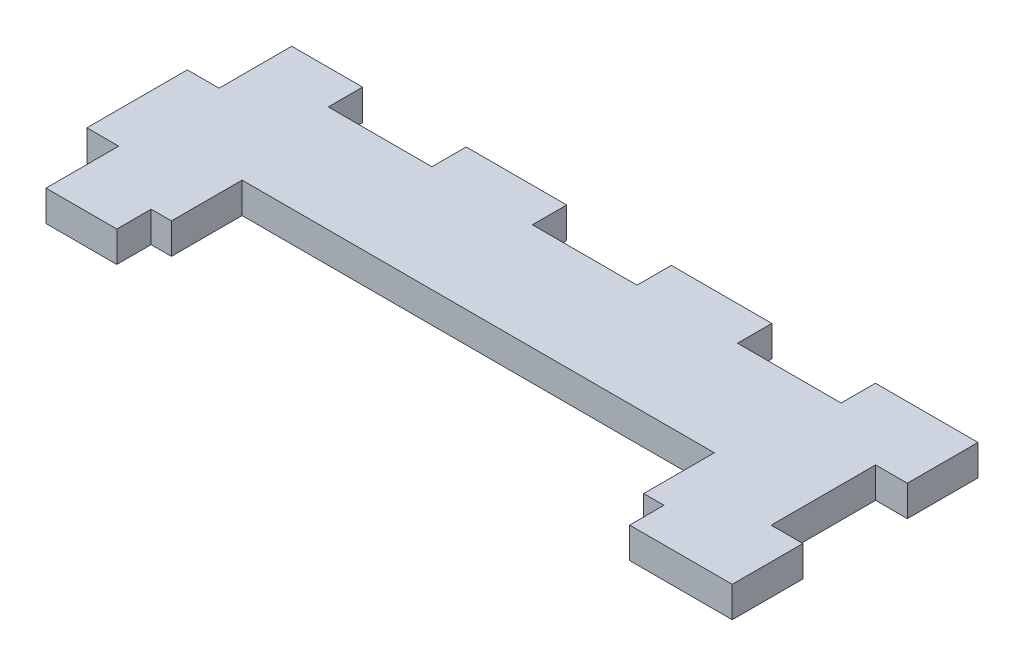
from build123d import *

# Parameters (mm, degrees)
BOSS_EXTRUDE1_DEPTH = 3


with BuildPart() as part:
    # Sketch3 → Boss-Extrude1 (new body)
    with BuildSketch(Plane(origin=(0, 0, 0), x_dir=(1, 0, 0), z_dir=(0, 1, 0))):
        Polygon((-35.058452488, 17.4), (-35.058452488, 7.6), (-31.958452488, 7.6), (-31.958452488, 0.5), (-25.041751777, 0.5), (-25.041751777, 3.85), (-23.058452488, 3.85), (-23.058452488, 10.75), (23.058452488, 10.75), (23.058452488, 3.85), (25.041751777, 3.85), (25.041751777, 0.5), (35.058452488, 0.5), (35.058452488, 7.4), (31.958452488, 7.4), (31.958452488, 17.6), (35.058452488, 17.6), (35.058452488, 24.5), (25.041751777, 24.5), (25.041751777, 21.15), (14.925051066, 21.15), (14.925051066, 24.5), (5.108350355, 24.5), (5.108350355, 21.15), (-5.108350355, 21.15), (-5.108350355, 24.5), (-14.925051066, 24.5), (-14.925051066, 21.15), (-25.041751777, 21.15), (-25.041751777, 24.5), (-31.958452488, 24.5), (-31.958452488, 17.4), align=None)
    extrude(amount=-BOSS_EXTRUDE1_DEPTH)


solid = part.part
